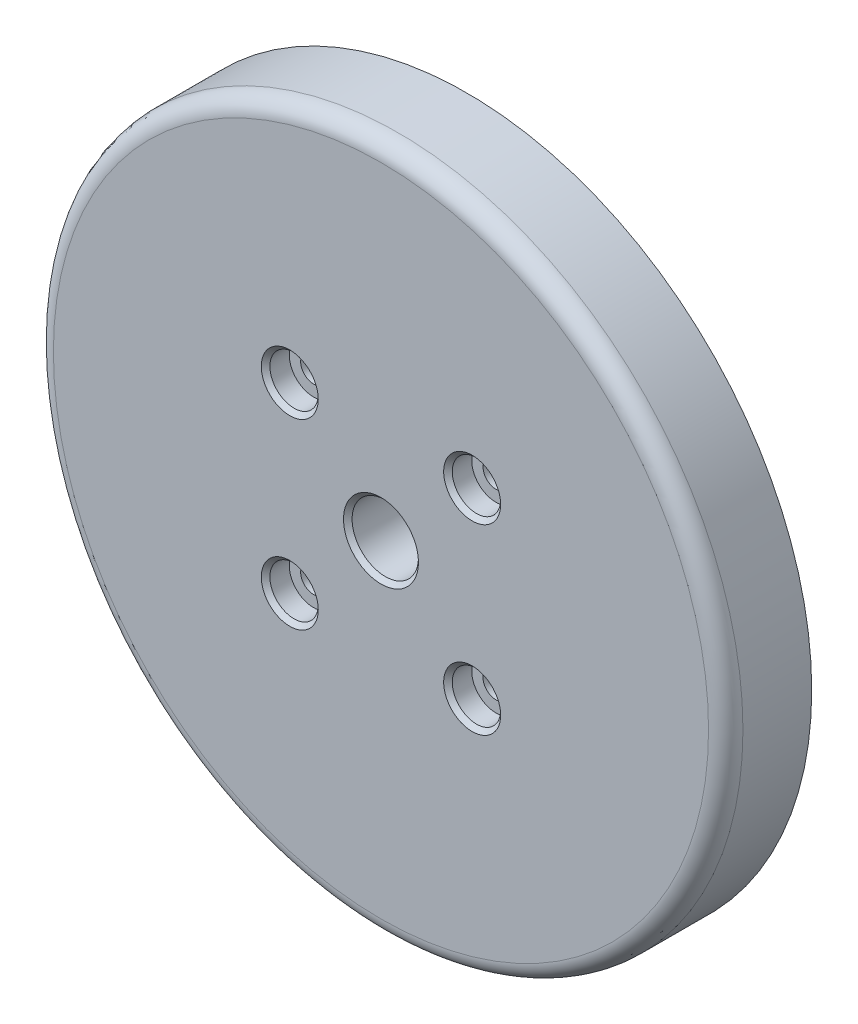
from build123d import *

# Parameters (mm, degrees)
SKETCH1_R                                     = 50.927
BOSS_EXTRUDE1_DEPTH                           = 12.7
W_0_386_DIAMETER_HOLE1_D                      = 9.8044
W_0_386_DIAMETER_HOLE1_CSINK_D                = 11.0744
W_0_386_DIAMETER_HOLE1_CSINK_ANGLE            = 90
CBORE_FOR_6_SOCKET_HEAD_CAP_SCREW1_AT_2_COUNT = 2
CBORE_FOR_6_SOCKET_HEAD_CAP_SCREW1_AT_2_PITCH = 38.1
CBORE_FOR_6_SOCKET_HEAD_CAP_SCREW1_AT_3_COUNT = 2
CBORE_FOR_6_SOCKET_HEAD_CAP_SCREW1_AT_3_PITCH = 26.940768363
CBORE_FOR_6_SOCKET_HEAD_CAP_SCREW1_AT_4_COUNT = 2
CBORE_FOR_6_SOCKET_HEAD_CAP_SCREW1_AT_4_PITCH = 26.940768363
FILLET1_R                                     = 2.54
SKETCH7_R                                     = 15.9385
SKETCH7_R_2                                   = 12.446
CUT_EXTRUDE2_DEPTH                            = 6.35
SKETCH6_R                                     = 38.1
CUT_EXTRUDE1_DEPTH                            = 4.826


with BuildPart() as part:
    # Sketch1 → Boss-Extrude1 (new body)
    with BuildSketch(Plane.XY):
        Circle(SKETCH1_R)
    extrude(amount=BOSS_EXTRUDE1_DEPTH)

    # W (0.386) Diameter Hole1 (through all)
    with Locations(Plane.XY.offset(12.7)):
        with Locations((0, 0)):
            CounterSinkHole(W_0_386_DIAMETER_HOLE1_D / 2, W_0_386_DIAMETER_HOLE1_CSINK_D / 2, counter_sink_angle=W_0_386_DIAMETER_HOLE1_CSINK_ANGLE)

    # Sketch5 → CBORE for #6 Socket Head Cap Screw1 (revolve, cut)
    with BuildSketch(Plane(origin=(13.470384182, 13.470384182, 12.7), x_dir=(0, -1, 0), z_dir=(1, 0, 0))):
        Polygon((0, 0), (0, 12.7), (1.89865, 12.7), (1.89865, 3.5052), (3.57251, 3.5052), (3.57251, 0.635), (4.20751, 0), align=None)
    cbore_for_6_socket_head_cap_screw1 = revolve(axis=Axis((13.470384182, 13.470384182, 19.05), (0, 0, -1)), mode=Mode.SUBTRACT)

    # CBORE for #6 Socket Head Cap Screw1 at 2: CBORE for #6 Socket Head Cap Screw1 ×2
    with Locations(*[Vector(-0.707106781, -0.707106781, 0) * (i * CBORE_FOR_6_SOCKET_HEAD_CAP_SCREW1_AT_2_PITCH) for i in range(1, CBORE_FOR_6_SOCKET_HEAD_CAP_SCREW1_AT_2_COUNT)]):
        add(cbore_for_6_socket_head_cap_screw1, mode=Mode.SUBTRACT)

    # CBORE for #6 Socket Head Cap Screw1 at 3: CBORE for #6 Socket Head Cap Screw1 ×2
    with Locations(*[(-i * CBORE_FOR_6_SOCKET_HEAD_CAP_SCREW1_AT_3_PITCH, 0, 0) for i in range(1, CBORE_FOR_6_SOCKET_HEAD_CAP_SCREW1_AT_3_COUNT)]):
        add(cbore_for_6_socket_head_cap_screw1, mode=Mode.SUBTRACT)

    # CBORE for #6 Socket Head Cap Screw1 at 4: CBORE for #6 Socket Head Cap Screw1 ×2
    with Locations(*[(0, -i * CBORE_FOR_6_SOCKET_HEAD_CAP_SCREW1_AT_4_PITCH, 0) for i in range(1, CBORE_FOR_6_SOCKET_HEAD_CAP_SCREW1_AT_4_COUNT)]):
        add(cbore_for_6_socket_head_cap_screw1, mode=Mode.SUBTRACT)

    # Fillet1
    fillet1_edges = [part.edges().sort_by_distance(p)[0] for p in [
        (-50.927, 0, 12.7),
    ]]
    fillet(fillet1_edges, radius=FILLET1_R)

    # Sketch7 → Cut-Extrude2 (cut)
    with BuildSketch(Plane(origin=(0, 0, 0), x_dir=(-1, 0, 0), z_dir=(0, 0, -1))):
        Circle(SKETCH7_R)
        Circle(SKETCH7_R_2, mode=Mode.SUBTRACT)
    extrude(amount=-CUT_EXTRUDE2_DEPTH, mode=Mode.SUBTRACT)

    # Sketch6 → Cut-Extrude1 (cut)
    with BuildSketch(Plane(origin=(0, 0, 0), x_dir=(-1, 0, 0), z_dir=(0, 0, -1))):
        Circle(SKETCH6_R)
    extrude(amount=-CUT_EXTRUDE1_DEPTH, mode=Mode.SUBTRACT)


solid = part.part
